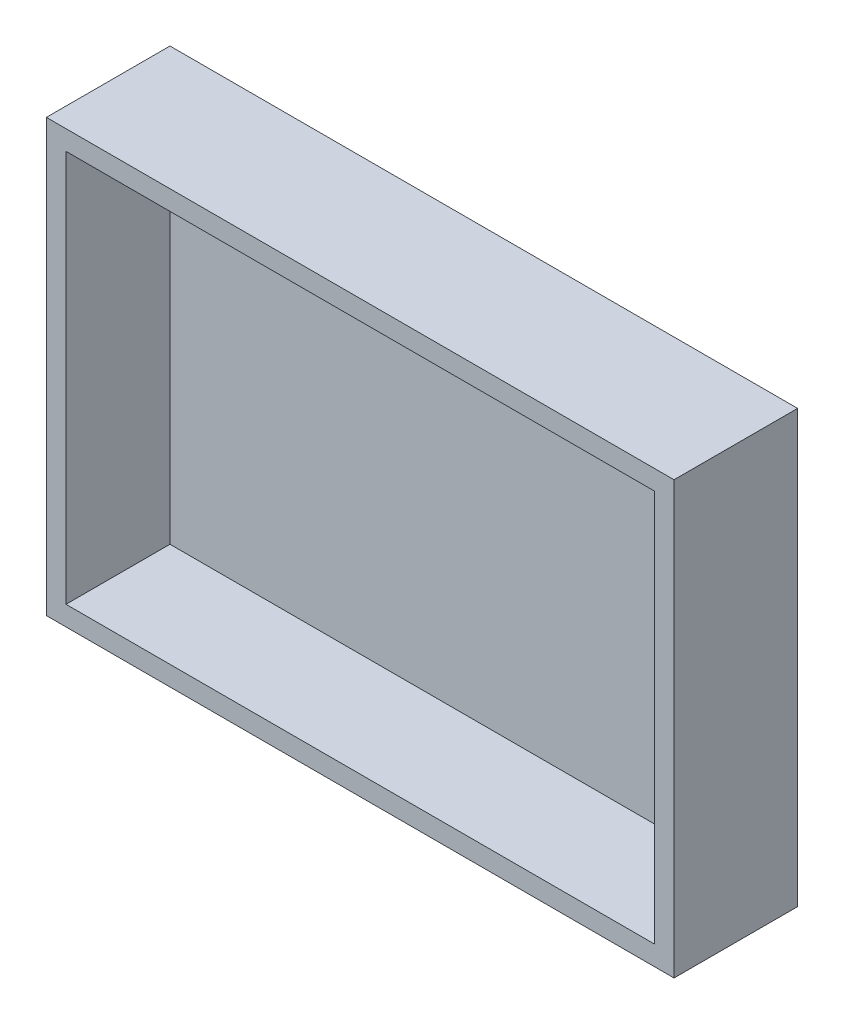
from build123d import *

# Parameters (mm, degrees)
SKETCH1_W           = 150
SKETCH1_H           = 100
BOSS_EXTRUDE1_DEPTH = 5
SKETCH2_W           = 150
SKETCH2_H           = 31.506784204
BOSS_EXTRUDE2_DEPTH = 5
SKETCH4_W           = 31.506784204
SKETCH4_H           = 105
BOSS_EXTRUDE3_DEPTH = 5
SKETCH5_W           = 155
SKETCH5_H           = 31.506784204
BOSS_EXTRUDE4_DEPTH = 5
SKETCH6_W           = 31.506784204
SKETCH6_H           = 110
BOSS_EXTRUDE5_DEPTH = 5


with BuildPart() as part:
    # Sketch1 → Boss-Extrude1 (new body)
    with BuildSketch(Plane.XY):
        Rectangle(SKETCH1_W, SKETCH1_H)
    extrude(amount=BOSS_EXTRUDE1_DEPTH)

    # Sketch2 → Boss-Extrude2 (add)
    with BuildSketch(Plane.XZ.offset(50)):
        with Locations((0, 15.753392102)):
            Rectangle(SKETCH2_W, SKETCH2_H)
    extrude(amount=BOSS_EXTRUDE2_DEPTH)

    # Sketch4 → Boss-Extrude3 (add)
    with BuildSketch(Plane(origin=(75, 0, 0), x_dir=(0, 0, -1), z_dir=(1, 0, 0))):
        with Locations((-15.753392102, -2.5)):
            Rectangle(SKETCH4_W, SKETCH4_H)
    extrude(amount=BOSS_EXTRUDE3_DEPTH)

    # Sketch5 → Boss-Extrude4 (add)
    with BuildSketch(Plane(origin=(0, 50, 0), x_dir=(1, 0, 0), z_dir=(0, 1, 0))):
        with Locations((2.5, -15.753392102)):
            Rectangle(SKETCH5_W, SKETCH5_H)
    extrude(amount=BOSS_EXTRUDE4_DEPTH)

    # Sketch6 → Boss-Extrude5 (add)
    with BuildSketch(Plane.ZY.offset(75)):
        with Locations((15.753392102, 0)):
            Rectangle(SKETCH6_W, SKETCH6_H)
    extrude(amount=BOSS_EXTRUDE5_DEPTH)


solid = part.part
